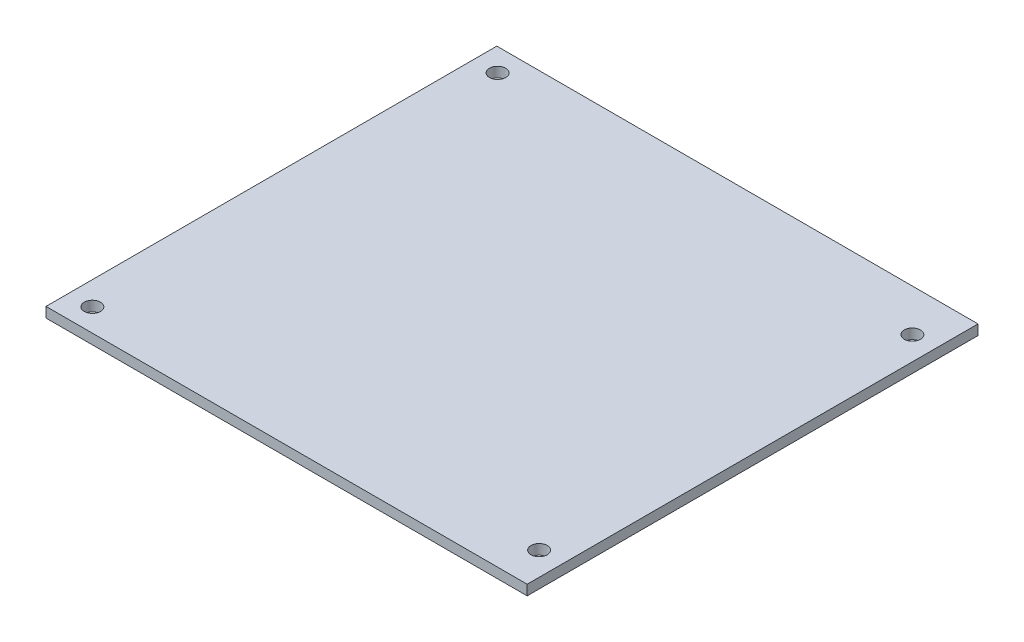
from build123d import *

# Parameters (mm, degrees)
SKETCH1_W           = 95
SKETCH1_H           = 89.01
SKETCH1_R           = 1.6
BOSS_EXTRUDE1_DEPTH = 2


with BuildPart() as part:
    # Sketch1 → Boss-Extrude1 (new body)
    with BuildSketch(Plane(origin=(0, 0, 0), x_dir=(1, 0, 0), z_dir=(0, 1, 0))):
        Rectangle(SKETCH1_W, SKETCH1_H)
        with Locations((-42.85, 40)):
            Circle(SKETCH1_R, mode=Mode.SUBTRACT)
        with Locations((42.85, 36.2)):
            Circle(SKETCH1_R, mode=Mode.SUBTRACT)
        with Locations((-42.85, -40)):
            Circle(SKETCH1_R, mode=Mode.SUBTRACT)
        with Locations((42.85, -37.5)):
            Circle(SKETCH1_R, mode=Mode.SUBTRACT)
    extrude(amount=BOSS_EXTRUDE1_DEPTH)


solid = part.part
